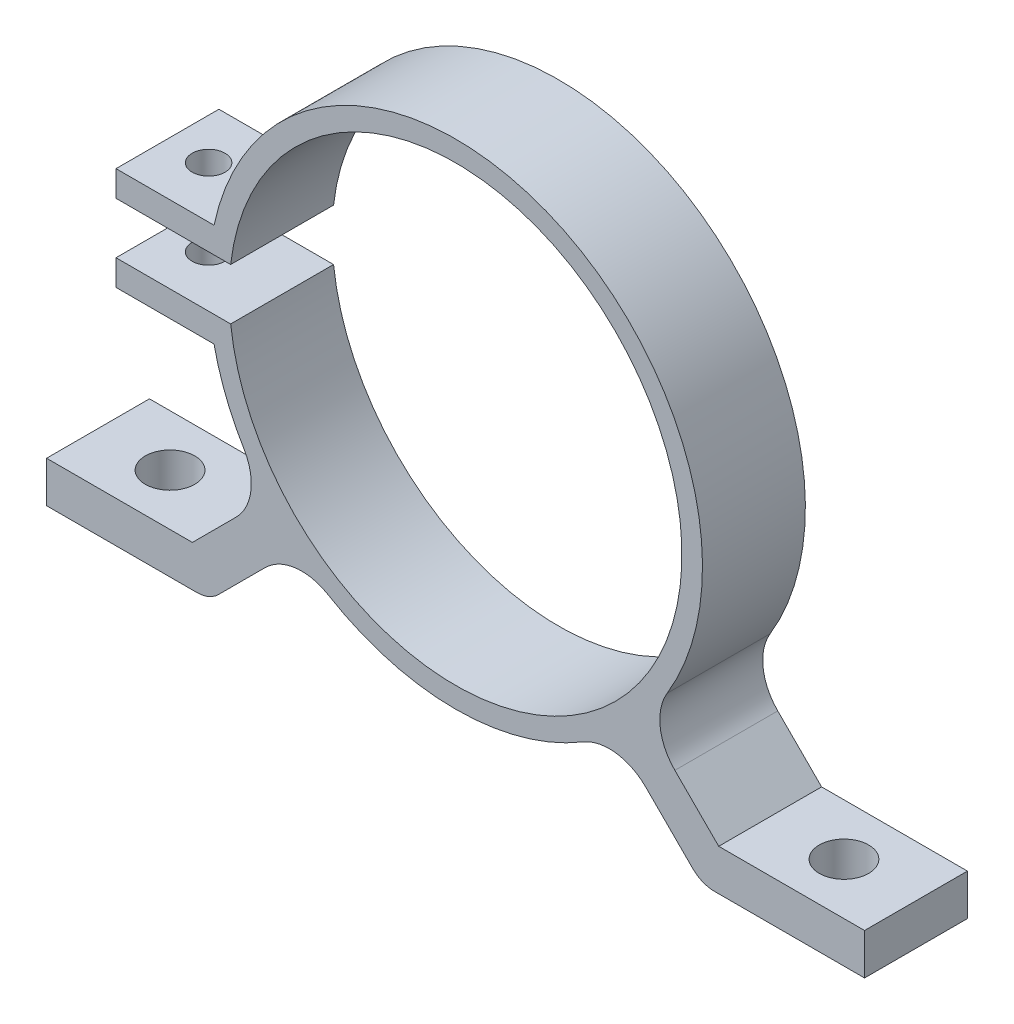
from build123d import *

# Parameters (mm, degrees)
SKETCH1_R               = 24
BOSS_EXTRUDE1_DEPTH     = 5
EXTRUDE_THIN1_DEPTH     = 5
SKETCH4_W               = 33
SKETCH4_H               = 10
BOSS_EXTRUDE2_DEPTH     = 5
SKETCH5_R               = 22
SKETCH5_W               = 33
SKETCH5_H               = 5
CUT_EXTRUDE1_DEPTH      = 26.5
SKETCH6_R               = 1.6
CUT_EXTRUDE2_DEPTH      = 20
CUT_EXTRUDE2_DEPTH_BACK = 10
SKETCH7_R               = 2.4
CUT_EXTRUDE3_DEPTH      = 5
FILLET3_R               = 5


with BuildPart() as part:
    # Sketch1 → Boss-Extrude1 (new body, symmetric)
    with BuildSketch(Plane.XY):
        Circle(SKETCH1_R)
    extrude(amount=BOSS_EXTRUDE1_DEPTH, both=True)

    # Sketch2 → Extrude-Thin1 (add, symmetric)
    with BuildSketch(Plane.XY):
        with BuildLine():
            Line((-39.748737342, -26.748737342), (-25.162950904, -26.748737342))
            ThreePointArc((-25.162950904, -26.748737342), (-24.014900607, -26.520375939), (-23.04163056, -25.870057685))
            Line((-23.04163056, -25.870057685), (0, -2.828427125))
            Line((0, -2.828427125), (23.04163056, -25.870057685))
            ThreePointArc((23.04163056, -25.870057685), (24.014900607, -26.520375939), (25.162950904, -26.748737342))
            Line((25.162950904, -26.748737342), (39.748737342, -26.748737342))
            Line((39.748737342, -26.748737342), (39.748737342, -22.748737342))
            Line((39.748737342, -22.748737342), (25.577164466, -22.748737342))
            Line((25.577164466, -22.748737342), (0, 2.828427125))
            Line((0, 2.828427125), (-25.577164466, -22.748737342))
            Line((-25.577164466, -22.748737342), (-39.748737342, -22.748737342))
            Line((-39.748737342, -22.748737342), (-39.748737342, -26.748737342))
        make_face()
    extrude(amount=EXTRUDE_THIN1_DEPTH, both=True)

    # Sketch4 → Boss-Extrude2 (add, symmetric)
    with BuildSketch(Plane.XY):
        with Locations((-16.5, 0)):
            Rectangle(SKETCH4_W, SKETCH4_H)
    extrude(amount=BOSS_EXTRUDE2_DEPTH, both=True)

    # Sketch5 → Cut-Extrude1 (cut)
    with BuildSketch(Plane.XY.offset(5)):
        Circle(SKETCH5_R)
        with Locations((-16.5, 0)):
            Rectangle(SKETCH5_W, SKETCH5_H)
    extrude(amount=-CUT_EXTRUDE1_DEPTH, mode=Mode.SUBTRACT)

    # Sketch6 → Cut-Extrude2 (cut, two sides)
    with BuildSketch(Plane(origin=(0, 5, 0), x_dir=(1, 0, 0), z_dir=(0, 1, 0))) as cut_extrude2_sk:
        with Locations((-29, 0)):
            Circle(SKETCH6_R)
    extrude(amount=CUT_EXTRUDE2_DEPTH, mode=Mode.SUBTRACT)
    extrude(cut_extrude2_sk.sketch, amount=-CUT_EXTRUDE2_DEPTH_BACK, mode=Mode.SUBTRACT)

    # Sketch7 → Cut-Extrude3 (cut, through all)
    with BuildSketch(Plane(origin=(0, -22.748737342, 0), x_dir=(1, 0, 0), z_dir=(0, 1, 0))):
        with Locations((-32.748737342, 0)):
            Circle(SKETCH7_R)
        with Locations((32.748737342, 0)):
            Circle(SKETCH7_R)
    extrude(amount=-CUT_EXTRUDE3_DEPTH, mode=Mode.SUBTRACT)

    # Fillet3
    fillet3_edges = [part.edges().sort_by_distance(p)[0] for p in [
        (-15.497320963, -18.325748088, 0),
        (15.497320963, -18.325748088, 0),
        (18.325748088, -15.497320963, 0),
        (-18.325748088, -15.497320963, 0),
    ]]
    fillet(fillet3_edges, radius=FILLET3_R)


solid = part.part
